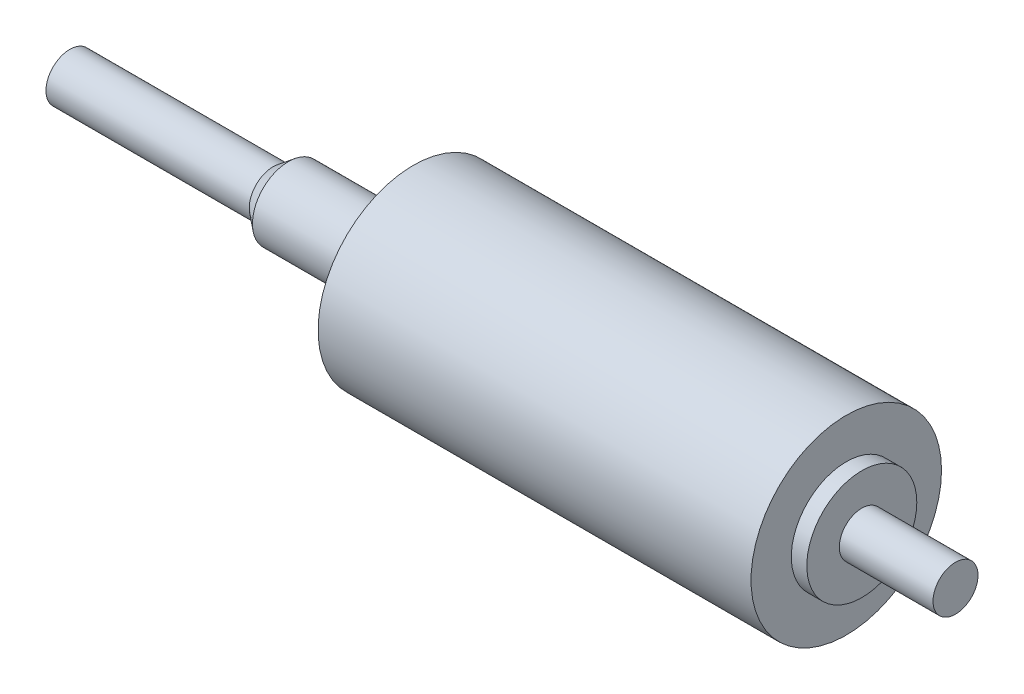
from build123d import *


with BuildPart() as part:
    # Sketch1 → Revolve1 (revolve)
    with BuildSketch(Plane.XY):
        Polygon((0, 6.2357), (28.3464, 6.2357), (28.3464, 3.60045), (29.3624, 3.60045), (29.3624, 1.4732), (35.4965, 1.4732), (35.4965, 0), (0, 0), (-22.4917, 0), (-22.4917, 1.5621), (-9.1821, 1.5621), (-8.1788, 2.35585), (0, 2.35585), align=None)
    revolve(axis=Axis((35.4965, 0, 0), (-1, 0, 0)))


solid = part.part
